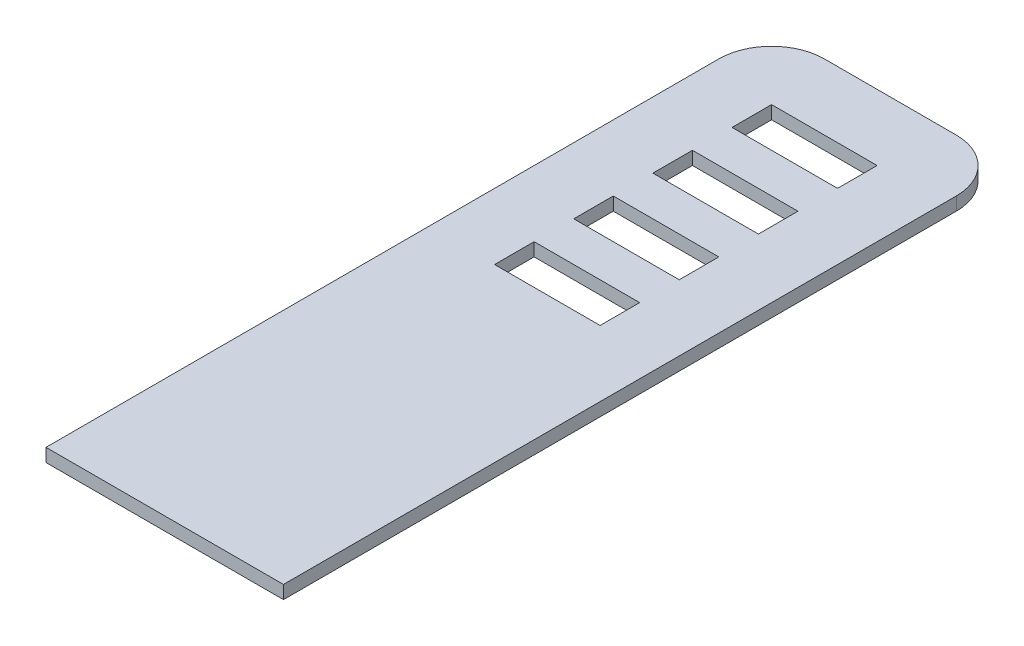
from build123d import *

# Parameters (mm, degrees)
SKETCH1_W           = 18
SKETCH1_H           = 55
BOSS_EXTRUDE1_DEPTH = 1
SKETCH2_W           = 7.6
SKETCH2_H           = 3.6
BOSS_EXTRUDE2_DEPTH = 1
SKETCH3_W           = 8
SKETCH3_H           = 3
CUT_EXTRUDE1_DEPTH  = 2
FILLET1_R           = 4


with BuildPart() as part:
    # Sketch1 → Boss-Extrude1 (new body)
    with BuildSketch(Plane(origin=(0, 0, 0), x_dir=(1, 0, 0), z_dir=(0, 1, 0))):
        with Locations((9, -27.5)):
            Rectangle(SKETCH1_W, SKETCH1_H)
    extrude(amount=BOSS_EXTRUDE1_DEPTH)

    # Sketch2 → Boss-Extrude2 (add)
    with BuildSketch(Plane.XZ):
        with Locations((9, 49)):
            Rectangle(SKETCH2_W, SKETCH2_H)
        with Locations((9, 39.6)):
            Rectangle(SKETCH2_W, SKETCH2_H)
    extrude(amount=BOSS_EXTRUDE2_DEPTH)

    # Sketch3 → Cut-Extrude1 (cut, through all)
    with BuildSketch(Plane.XZ):
        with Locations((9, 12.5)):
            Rectangle(SKETCH3_W, SKETCH3_H)
        with Locations((9, 6.5)):
            Rectangle(SKETCH3_W, SKETCH3_H)
        with Locations((9, 18.5)):
            Rectangle(SKETCH3_W, SKETCH3_H)
        with Locations((9, 24.5)):
            Rectangle(SKETCH3_W, SKETCH3_H)
    extrude(amount=-CUT_EXTRUDE1_DEPTH, mode=Mode.SUBTRACT)

    # Fillet1
    fillet1_edges = [part.edges().sort_by_distance(p)[0] for p in [
        (0, 0.5, 0),
        (18, 0.5, 0),
    ]]
    fillet(fillet1_edges, radius=FILLET1_R)


solid = part.part
